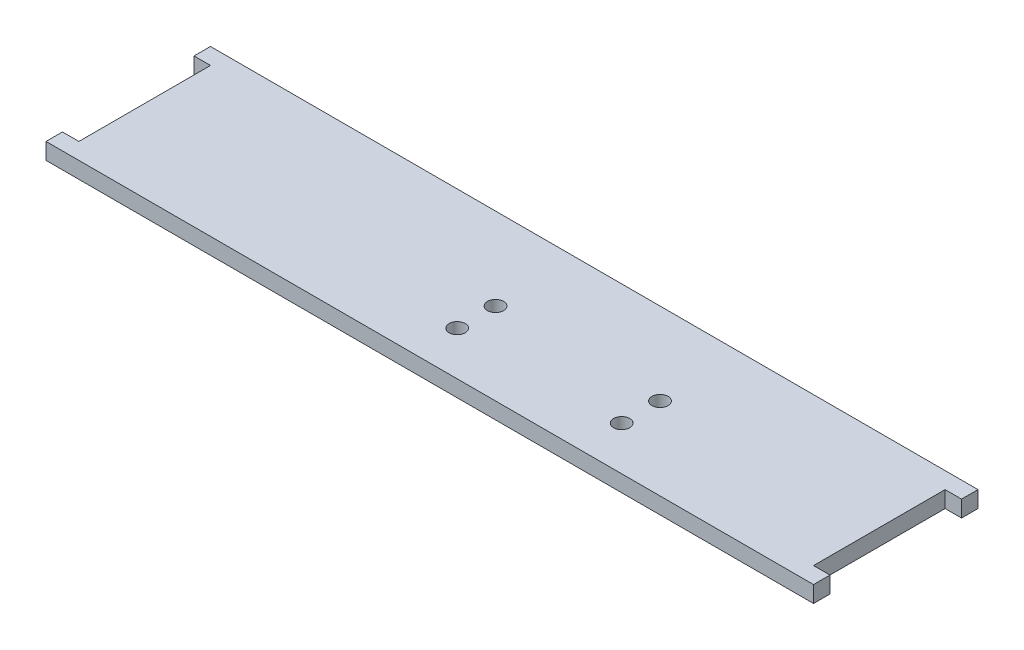
from build123d import *

# Parameters (mm, degrees)
SKETCH1_W           = 140
SKETCH1_H           = 30
BOSS_EXTRUDE1_DEPTH = 3
SKETCH2_W           = 3
SKETCH2_H           = 24
CUT_EXTRUDE1_DEPTH  = 3
SKETCH3_R           = 1.47
CUT_EXTRUDE2_DEPTH  = 3


with BuildPart() as part:
    # Sketch1 → Boss-Extrude1 (new body)
    with BuildSketch(Plane(origin=(0, 0, 0), x_dir=(1, 0, 0), z_dir=(0, 1, 0))):
        Rectangle(SKETCH1_W, SKETCH1_H)
    extrude(amount=BOSS_EXTRUDE1_DEPTH)

    # Sketch2 → Cut-Extrude1 (cut)
    with BuildSketch(Plane(origin=(0, 3, 0), x_dir=(1, 0, 0), z_dir=(0, 1, 0))):
        with Locations((-68.5, 0)):
            Rectangle(SKETCH2_W, SKETCH2_H)
        with Locations((68.5, 0)):
            Rectangle(SKETCH2_W, SKETCH2_H)
    extrude(amount=-CUT_EXTRUDE1_DEPTH, mode=Mode.SUBTRACT)

    # Sketch3 → Cut-Extrude2 (cut)
    with BuildSketch(Plane(origin=(0, 3, 0), x_dir=(1, 0, 0), z_dir=(0, 1, 0))):
        with Locations((-3, 0)):
            Circle(SKETCH3_R)
        with Locations((-3, -7)):
            Circle(SKETCH3_R)
        with Locations((27, 0)):
            Circle(SKETCH3_R)
        with Locations((27, -7)):
            Circle(SKETCH3_R)
    extrude(amount=-CUT_EXTRUDE2_DEPTH, mode=Mode.SUBTRACT)


solid = part.part
